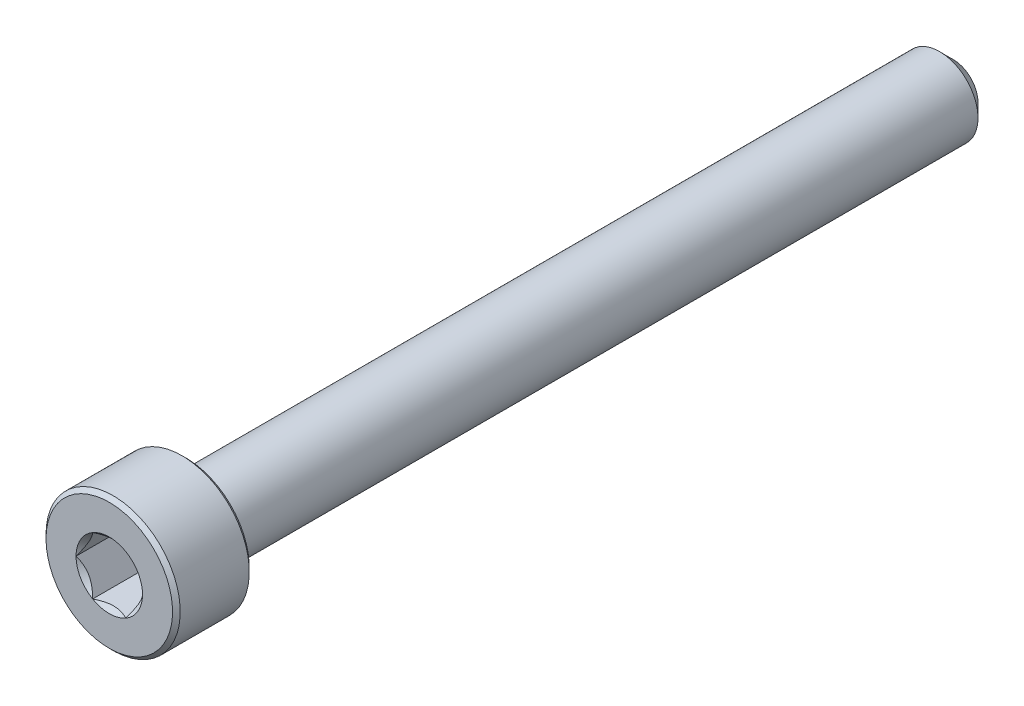
from build123d import *

# Parameters (mm, degrees)
CUT_EXTRUDE1_DEPTH = 3
SKETCH4_R          = 1.732050808
CUT_EXTRUDE2_DEPTH = 3
CUT_EXTRUDE2_DRAFT = -45


with BuildPart() as part:
    # Sketch2 → Revolve1 (revolve)
    with BuildSketch(Plane(origin=(0, 0, 0), x_dir=(0, 0, -1), z_dir=(1, 0, 0))):
        Polygon((-22, 0), (-22, 3.3), (-21.8, 3.5), (-18.2, 3.5), (-18, 3.3), (-18, 2), (21.3, 2), (22, 1.3), (22, 0), align=None)
    revolve(axis=Axis((0, 0, -22), (0, 0, 1)))

    # Sketch3 → Cut-Extrude1 (cut)
    with BuildSketch(Plane.XY.offset(22)):
        Polygon((0.866025404, 1.5), (-0.866025404, 1.5), (-1.732050808, 0), (-0.866025404, -1.5), (0.866025404, -1.5), (1.732050808, 0), align=None)
    extrude(amount=-CUT_EXTRUDE1_DEPTH, mode=Mode.SUBTRACT)


with BuildPart() as cut_extrude2_tool:
    # Sketch4 → Cut-Extrude2 (with draft: the straight prism first)
    with BuildSketch(Plane.XY.offset(22)):
        Circle(SKETCH4_R)
    extrude(amount=-CUT_EXTRUDE2_DEPTH)
    # Cut-Extrude2: the draft: its side faces are tilted about the plane it starts from
    cut_extrude2_sides = [cut_extrude2_tool.faces().sort_by_distance(p)[0] for p in [
        (-1.732050808, 0, 20.5),
    ]]
    draft(cut_extrude2_sides, Plane.XY.offset(22), CUT_EXTRUDE2_DRAFT)


with BuildPart() as part_1:
    add(part.part)

    # Cut-Extrude2: cut by cut_extrude2_tool
    add(cut_extrude2_tool.part, mode=Mode.SUBTRACT)


solid = part_1.part
